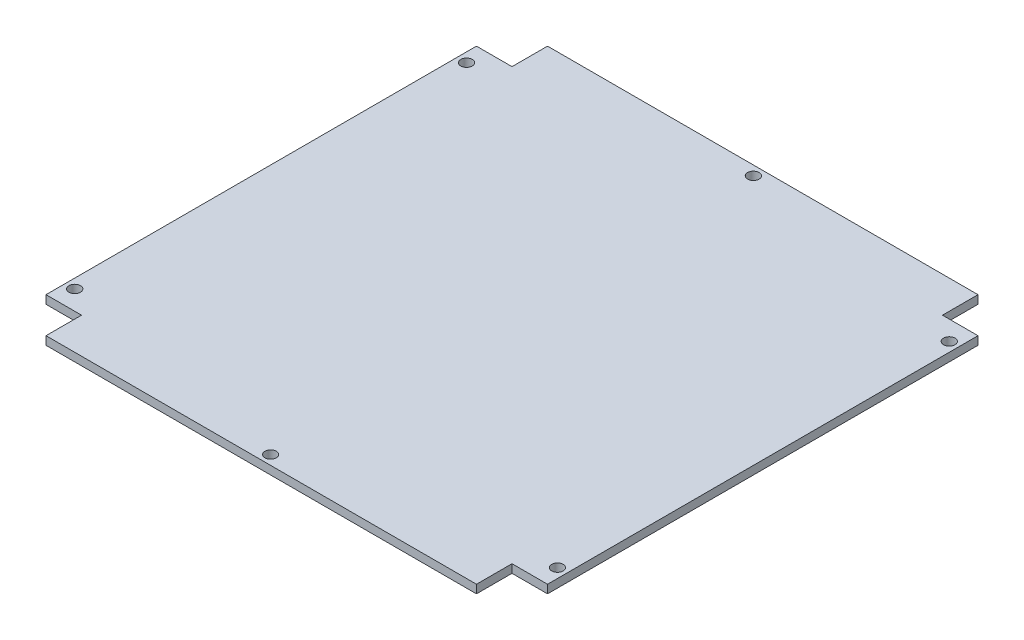
from build123d import *

# Parameters (mm, degrees)
BOSS_EXTRUDE1_DEPTH            = 1.6
F_2_2_2_2_DIAMETER_HOLE1_D     = 2.2
F_2_2_2_2_DIAMETER_HOLE1_DEPTH = 5
SKETCH8_W                      = 82.4
SKETCH8_H                      = 0.2
SKETCH8_W_2                    = 0.2
SKETCH8_H_2                    = 82.4
EXTRUDE1_DEPTH                 = 2.6


with BuildPart() as part:
    # Sketch1 → Boss-Extrude1 (new body)
    with BuildSketch(Plane(origin=(0, 0, 0), x_dir=(1, 0, 0), z_dir=(0, 1, 0))):
        Polygon((-34.144384454, 27.628503563), (-27.144384454, 27.628503563), (-27.144384454, 34.628503563), (55.255615546, 34.628503563), (55.255615546, 27.628503563), (62.255615546, 27.628503563), (62.255615546, -54.771496437), (55.255615546, -54.771496437), (55.255615546, -61.771496437), (-27.144384454, -61.771496437), (-27.144384454, -54.771496437), (-34.144384454, -54.771496437), align=None)
    extrude(amount=BOSS_EXTRUDE1_DEPTH)

    # Ø2.2 (2.2) Diameter Hole1
    with Locations(Plane(origin=(0, 1.6, 0), x_dir=(1, 0, 0), z_dir=(0, 1, 0))):
        with Locations((14.055615546, 32.628503563), (14.055615546, -59.771496437), (-32.144384454, -51.071496437), (60.255615546, 23.928503563), (-32.144384454, 23.928503563), (60.255615546, -51.071496437)):
            Hole(F_2_2_2_2_DIAMETER_HOLE1_D / 2, depth=F_2_2_2_2_DIAMETER_HOLE1_DEPTH)

    # Sketch8 → Extrude1 (cut, through all)
    with BuildSketch(Plane(origin=(0, 1.6, 0), x_dir=(1, 0, 0), z_dir=(0, 1, 0))):
        with Locations((14.055615546, 34.528503563)):
            Rectangle(SKETCH8_W, SKETCH8_H)
        with Locations((62.155615546, -13.571496437)):
            Rectangle(SKETCH8_W_2, SKETCH8_H_2)
        with Locations((14.055615546, -61.671496437)):
            Rectangle(SKETCH8_W, SKETCH8_H)
        with Locations((-34.044384454, -13.571496437)):
            Rectangle(SKETCH8_W_2, SKETCH8_H_2)
    extrude(amount=-EXTRUDE1_DEPTH, mode=Mode.SUBTRACT)


solid = part.part
